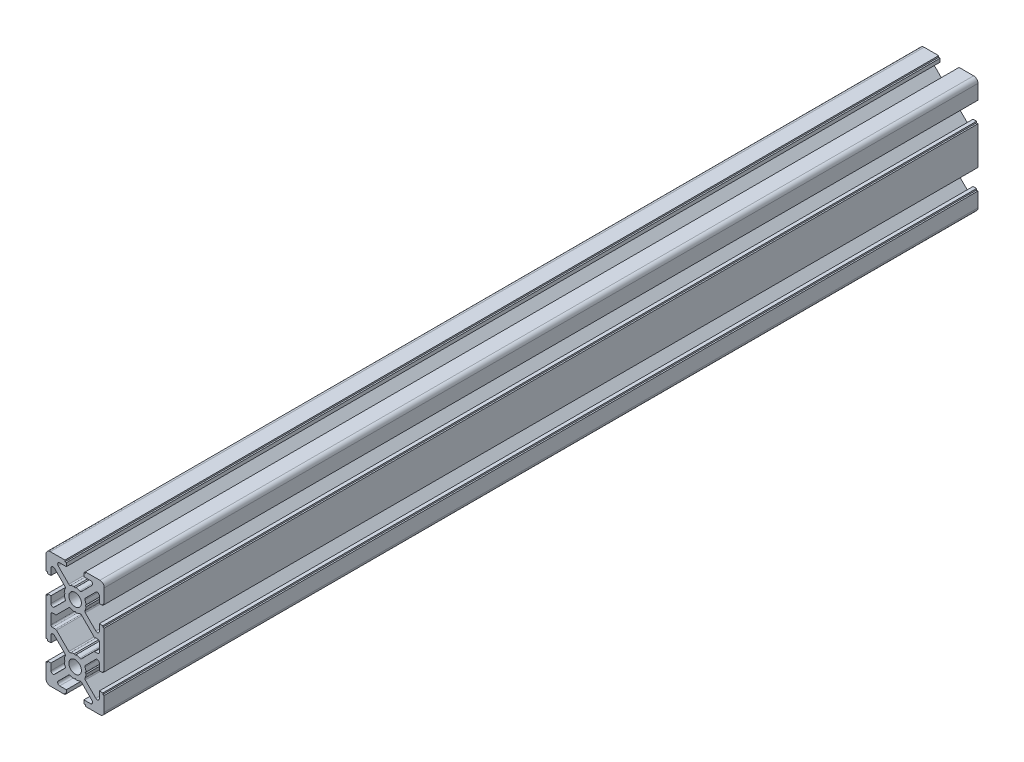
from build123d import *

# Parameters (mm, degrees)
SKETCH1_R           = 2.15
BOSS_EXTRUDE1_DEPTH = 300


with BuildPart() as part:
    # Sketch1 → Boss-Extrude1 (new body)
    with BuildSketch(Plane.XY.offset(100)):
        with BuildLine():
            Line((2.999999948, 19.5), (2.999999948, 18.30000003))
            Line((2.999999948, 18.30000003), (5.299390298, 18.30000003))
            ThreePointArc((5.299390298, 18.30000003), (5.946105969, 17.867878435), (5.794365047, 17.105025288))
            Line((5.794365047, 17.105025288), (2.175465586, 13.486125796))
            ThreePointArc((2.175465586, 13.486125796), (1.907085095, 13.346987012), (1.607569585, 13.387952225))
            ThreePointArc((1.607569585, 13.387952225), (0.969708948, 13.62245287), (0.300000018, 13.737980766))
            Line((0.300000018, 13.737980766), (1.9e-08, 13.450000028))
            Line((1.9e-08, 13.450000028), (-0.299999982, 13.737980766))
            ThreePointArc((-0.299999982, 13.737980766), (-0.969708911, 13.62245287), (-1.607569547, 13.387952225))
            ThreePointArc((-1.607569547, 13.387952225), (-1.907085057, 13.346987012), (-2.175465548, 13.486125795))
            Line((-2.175465548, 13.486125795), (-5.794365007, 17.105025286))
            ThreePointArc((-5.794365007, 17.105025286), (-5.94610593, 17.867878434), (-5.299390258, 18.30000003))
            Line((-5.299390258, 18.30000003), (-2.999999948, 18.30000003))
            Line((-2.999999948, 18.30000003), (-2.999999948, 19.5))
            Line((-2.999999948, 19.5), (-3.499999948, 19.5))
            Line((-3.499999948, 19.5), (-3.499999948, 20))
            Line((-3.499999948, 20), (-8.499999948, 20))
            ThreePointArc((-8.499999948, 20), (-9.56066012, 19.560660172), (-9.999999948, 18.5))
            Line((-9.999999948, 18.5), (-9.999999948, 13.5))
            Line((-9.999999948, 13.5), (-9.499999948, 13.5))
            Line((-9.499999948, 13.5), (-9.499999948, 13))
            Line((-9.499999948, 13), (-8.299999931, 13))
            Line((-8.299999931, 13), (-8.299999931, 15.299390328))
            ThreePointArc((-8.299999931, 15.299390328), (-7.867878339, 15.946105994), (-7.105025198, 15.79436507))
            Line((-7.105025198, 15.79436507), (-3.486125739, 12.175465611))
            ThreePointArc((-3.486125739, 12.175465611), (-3.346986957, 11.907085119), (-3.387952171, 11.607569609))
            ThreePointArc((-3.387952171, 11.607569609), (-3.622452821, 10.969708966), (-3.737980719, 10.30000003))
            Line((-3.737980719, 10.30000003), (-3.449999981, 10.000000028))
            Line((-3.449999981, 10.000000028), (-3.737980719, 9.700000028))
            ThreePointArc((-3.737980719, 9.700000028), (-3.622452819, 9.030291083), (-3.387952164, 8.392430432))
            ThreePointArc((-3.387952164, 8.392430432), (-3.346986948, 8.092914922), (-3.48612573, 7.82453443))
            Line((-3.48612573, 7.82453443), (-7.105025183, 4.205634944))
            ThreePointArc((-7.105025183, 4.205634944), (-7.867878333, 4.053894016), (-8.299999931, 4.700609688))
            Line((-8.299999931, 4.700609688), (-8.299999931, 7))
            Line((-8.299999931, 7), (-9.499999948, 7))
            Line((-9.499999948, 7), (-9.499999948, 6.5))
            Line((-9.499999948, 6.5), (-9.999999948, 6.5))
            Line((-9.999999948, 6.5), (-9.999999948, -6.5))
            Line((-9.999999948, -6.5), (-9.499999948, -6.5))
            Line((-9.499999948, -6.5), (-9.499999948, -7))
            Line((-9.499999948, -7), (-8.299999931, -7))
            Line((-8.299999931, -7), (-8.299999931, -4.700609673))
            ThreePointArc((-8.299999931, -4.700609673), (-7.867878338, -4.053894007), (-7.105025197, -4.205634931))
            Line((-7.105025197, -4.205634931), (-3.486125739, -7.824534389))
            ThreePointArc((-3.486125739, -7.824534389), (-3.346986957, -8.092914881), (-3.387952171, -8.392430391))
            ThreePointArc((-3.387952171, -8.392430391), (-3.622452821, -9.030291034), (-3.737980719, -9.69999997))
            Line((-3.737980719, -9.69999997), (-3.449999981, -9.999999972))
            Line((-3.449999981, -9.999999972), (-3.737980719, -10.299999973))
            ThreePointArc((-3.737980719, -10.299999973), (-3.622452819, -10.969708918), (-3.387952164, -11.607569568))
            ThreePointArc((-3.387952164, -11.607569568), (-3.346986948, -11.907085077), (-3.48612573, -12.17546557))
            Line((-3.48612573, -12.17546557), (-7.105025182, -15.794365055))
            ThreePointArc((-7.105025182, -15.794365055), (-7.867878332, -15.946105983), (-8.299999931, -15.29939031))
            Line((-8.299999931, -15.29939031), (-8.299999931, -13))
            Line((-8.299999931, -13), (-9.499999948, -13))
            Line((-9.499999948, -13), (-9.499999948, -13.5))
            Line((-9.499999948, -13.5), (-9.999999948, -13.5))
            Line((-9.999999948, -13.5), (-9.999999948, -18.5))
            ThreePointArc((-9.999999948, -18.5), (-9.56066012, -19.560660172), (-8.499999948, -20))
            Line((-8.499999948, -20), (-3.499999948, -20))
            Line((-3.499999948, -20), (-3.499999948, -19.5))
            Line((-3.499999948, -19.5), (-2.999999948, -19.5))
            Line((-2.999999948, -19.5), (-2.999999948, -18.299999975))
            Line((-2.999999948, -18.299999975), (-5.299390257, -18.299999975))
            ThreePointArc((-5.299390257, -18.299999975), (-5.94610593, -17.867878379), (-5.794365006, -17.10502523))
            Line((-5.794365006, -17.10502523), (-2.175465548, -13.48612574))
            ThreePointArc((-2.175465548, -13.48612574), (-1.907085057, -13.346986956), (-1.607569547, -13.387952169))
            ThreePointArc((-1.607569547, -13.387952169), (-0.969708911, -13.622452814), (-0.299999982, -13.73798071))
            Line((-0.299999982, -13.73798071), (1.9e-08, -13.449999972))
            Line((1.9e-08, -13.449999972), (0.300000018, -13.73798071))
            ThreePointArc((0.300000018, -13.73798071), (0.969708956, -13.622452812), (1.6075696, -13.387952162))
            ThreePointArc((1.6075696, -13.387952162), (1.90708511, -13.346986948), (2.175465602, -13.48612573))
            Line((2.175465602, -13.48612573), (5.794365087, -17.105025216))
            ThreePointArc((5.794365087, -17.105025216), (5.946106015, -17.867878373), (5.299390336, -18.299999975))
            Line((5.299390336, -18.299999975), (2.999999948, -18.299999975))
            Line((2.999999948, -18.299999975), (2.999999948, -19.5))
            Line((2.999999948, -19.5), (3.499999948, -19.5))
            Line((3.499999948, -19.5), (3.499999948, -20))
            Line((3.499999948, -20), (8.499999948, -20))
            ThreePointArc((8.499999948, -20), (9.56066012, -19.560660172), (9.999999948, -18.5))
            Line((9.999999948, -18.5), (9.999999948, -13.5))
            Line((9.999999948, -13.5), (9.499999948, -13.5))
            Line((9.499999948, -13.5), (9.499999948, -13))
            Line((9.499999948, -13), (8.299999969, -13))
            Line((8.299999969, -13), (8.299999969, -15.29939031))
            ThreePointArc((8.299999969, -15.29939031), (7.86787837, -15.946105983), (7.10502522, -15.794365055))
            Line((7.10502522, -15.794365055), (3.486125768, -12.17546557))
            ThreePointArc((3.486125768, -12.17546557), (3.346986986, -11.907085078), (3.387952202, -11.607569568))
            ThreePointArc((3.387952202, -11.607569568), (3.622452857, -10.969708917), (3.737980757, -10.299999972))
            Line((3.737980757, -10.299999972), (3.450000019, -9.999999972))
            Line((3.450000019, -9.999999972), (3.737980758, -9.699999972))
            ThreePointArc((3.737980758, -9.699999972), (3.622452857, -9.030291027), (3.387952202, -8.392430376))
            ThreePointArc((3.387952202, -8.392430376), (3.346986986, -8.092914866), (3.486125768, -7.824534374))
            Line((3.486125768, -7.824534374), (7.105025219, -4.205634891))
            ThreePointArc((7.105025219, -4.205634891), (7.86787837, -4.053893962), (8.299999969, -4.700609636))
            Line((8.299999969, -4.700609636), (8.299999969, -7))
            Line((8.299999969, -7), (9.499999948, -7))
            Line((9.499999948, -7), (9.499999948, -6.5))
            Line((9.499999948, -6.5), (9.999999948, -6.5))
            Line((9.999999948, -6.5), (9.999999948, 6.5))
            Line((9.999999948, 6.5), (9.499999948, 6.5))
            Line((9.499999948, 6.5), (9.499999948, 7))
            Line((9.499999948, 7), (8.299999969, 7))
            Line((8.299999969, 7), (8.299999969, 4.700609689))
            ThreePointArc((8.299999969, 4.700609689), (7.86787837, 4.053894016), (7.10502522, 4.205634945))
            Line((7.10502522, 4.205634945), (3.486125767, 7.82453443))
            ThreePointArc((3.486125767, 7.82453443), (3.346986986, 8.092914922), (3.387952202, 8.392430432))
            ThreePointArc((3.387952202, 8.392430432), (3.622452857, 9.030291083), (3.737980757, 9.700000028))
            Line((3.737980757, 9.700000028), (3.450000019, 10.000000028))
            Line((3.450000019, 10.000000028), (3.737980757, 10.300000031))
            ThreePointArc((3.737980757, 10.300000031), (3.622452856, 10.969708975), (3.387952202, 11.607569624))
            ThreePointArc((3.387952202, 11.607569624), (3.346986986, 11.907085133), (3.486125767, 12.175465626))
            Line((3.486125767, 12.175465626), (7.105025219, 15.794365109))
            ThreePointArc((7.105025219, 15.794365109), (7.86787837, 15.946106038), (8.299999969, 15.299390364))
            Line((8.299999969, 15.299390364), (8.299999969, 13))
            Line((8.299999969, 13), (9.499999948, 13))
            Line((9.499999948, 13), (9.499999948, 13.5))
            Line((9.499999948, 13.5), (9.999999948, 13.5))
            Line((9.999999948, 13.5), (9.999999948, 18.5))
            ThreePointArc((9.999999948, 18.5), (9.56066012, 19.560660172), (8.499999948, 20))
            Line((8.499999948, 20), (3.499999948, 20))
            Line((3.499999948, 20), (3.499999948, 19.5))
            Line((3.499999948, 19.5), (2.999999948, 19.5))
        make_face()
        with Locations((1.9e-08, 10.000000028)):
            Circle(SKETCH1_R, mode=Mode.SUBTRACT)
        with Locations((1.9e-08, -9.999999972)):
            Circle(SKETCH1_R, mode=Mode.SUBTRACT)
        with BuildLine():
            Line((2.175465602, 6.51387427), (6.392283572, 2.297056299))
            ThreePointArc((6.392283572, 2.297056299), (6.554495247, 2.188669924), (6.745836963, 2.15060969))
            Line((6.745836963, 2.15060969), (7.799999969, 2.15060969))
            ThreePointArc((7.799999969, 2.15060969), (8.15355336, 2.004163081), (8.299999969, 1.65060969))
            Line((8.299999969, 1.65060969), (8.299999969, -1.650609648))
            ThreePointArc((8.299999969, -1.650609648), (8.15355336, -2.004163039), (7.799999969, -2.150609648))
            Line((7.799999969, -2.150609648), (6.745836886, -2.150609648))
            ThreePointArc((6.745836886, -2.150609648), (6.554495169, -2.188669882), (6.392283494, -2.297056259))
            Line((6.392283494, -2.297056259), (2.175465586, -6.513874204))
            ThreePointArc((2.175465586, -6.513874204), (1.907085095, -6.653012988), (1.607569585, -6.612047775))
            ThreePointArc((1.607569585, -6.612047775), (0.969708948, -6.37754713), (0.300000019, -6.262019234))
            Line((0.300000019, -6.262019234), (1.9e-08, -6.549999972))
            Line((1.9e-08, -6.549999972), (-0.299999981, -6.262019234))
            ThreePointArc((-0.299999981, -6.262019234), (-0.96970891, -6.37754713), (-1.607569547, -6.612047775))
            ThreePointArc((-1.607569547, -6.612047775), (-1.907085057, -6.653012988), (-2.175465548, -6.513874204))
            Line((-2.175465548, -6.513874204), (-6.392283456, -2.297056259))
            ThreePointArc((-6.392283456, -2.297056259), (-6.554495131, -2.188669882), (-6.745836848, -2.150609648))
            Line((-6.745836848, -2.150609648), (-7.799999931, -2.150609648))
            ThreePointArc((-7.799999931, -2.150609648), (-8.153553322, -2.004163039), (-8.299999931, -1.650609648))
            Line((-8.299999931, -1.650609648), (-8.299999931, 1.65060969))
            ThreePointArc((-8.299999931, 1.65060969), (-8.153553322, 2.004163081), (-7.799999931, 2.15060969))
            Line((-7.799999931, 2.15060969), (-6.745836862, 2.15060969))
            ThreePointArc((-6.745836862, 2.15060969), (-6.554495145, 2.188669924), (-6.39228347, 2.297056301))
            Line((-6.39228347, 2.297056301), (-2.175465548, 6.51387426))
            ThreePointArc((-2.175465548, 6.51387426), (-1.907085057, 6.653013044), (-1.607569547, 6.612047831))
            ThreePointArc((-1.607569547, 6.612047831), (-0.96970891, 6.377547186), (-0.299999981, 6.262019289))
            Line((-0.299999981, 6.262019289), (1.9e-08, 6.550000028))
            Line((1.9e-08, 6.550000028), (0.300000019, 6.262019289))
            ThreePointArc((0.300000019, 6.262019289), (0.969708956, 6.377547188), (1.6075696, 6.612047838))
            ThreePointArc((1.6075696, 6.612047838), (1.90708511, 6.653013052), (2.175465602, 6.51387427))
        make_face(mode=Mode.SUBTRACT)
    extrude(amount=-BOSS_EXTRUDE1_DEPTH)


solid = part.part
